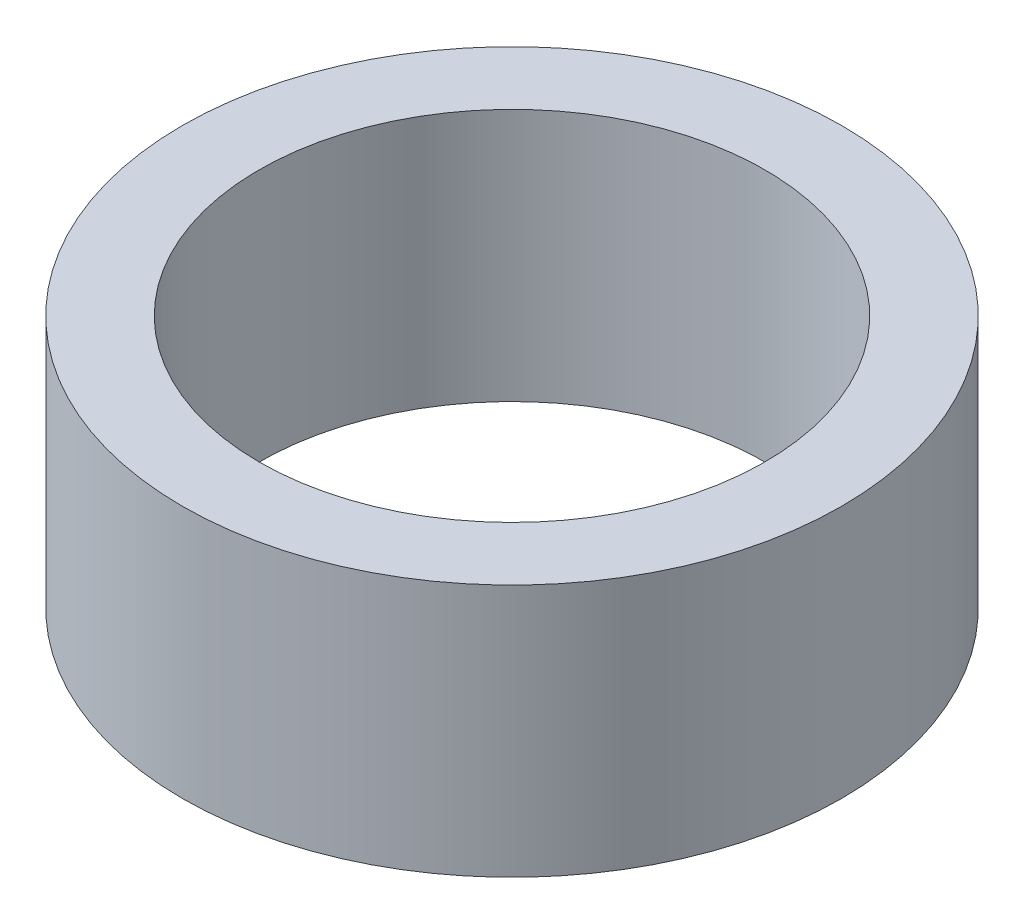
from build123d import *

# Parameters (mm, degrees)
SKETCH1_R           = 24
SKETCH1_R_2         = 18.415
BOSS_EXTRUDE1_DEPTH = 18.422


with BuildPart() as part:
    # Sketch1 → Boss-Extrude1 (new body)
    with BuildSketch(Plane(origin=(0, 0, 0), x_dir=(1, 0, 0), z_dir=(0, 1, 0))):
        Circle(SKETCH1_R)
        Circle(SKETCH1_R_2, mode=Mode.SUBTRACT)
    extrude(amount=BOSS_EXTRUDE1_DEPTH)


solid = part.part
